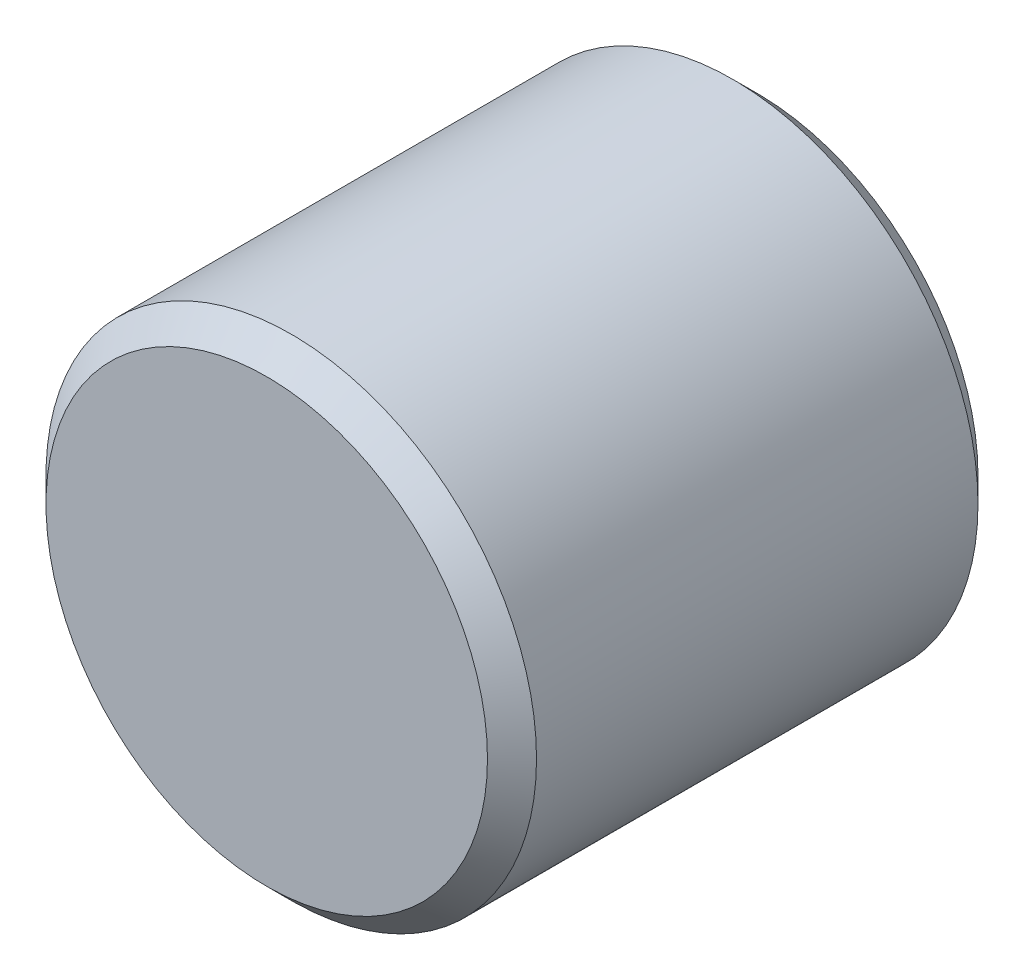
from build123d import *

# Parameters (mm, degrees)
SKETCH1_R           = 1.27
BOSS_EXTRUDE1_DEPTH = 2.54
CHAMFER1_SIZE       = 0.127


with BuildPart() as part:
    # Sketch1 → Boss-Extrude1 (new body)
    with BuildSketch(Plane.XY):
        Circle(SKETCH1_R)
    extrude(amount=BOSS_EXTRUDE1_DEPTH)

    # Chamfer1
    chamfer1_edges = [part.edges().sort_by_distance(p)[0] for p in [
        (-1.27, 0, 0),
        (-1.27, 0, 2.54),
    ]]
    chamfer(chamfer1_edges, length=CHAMFER1_SIZE)


solid = part.part
